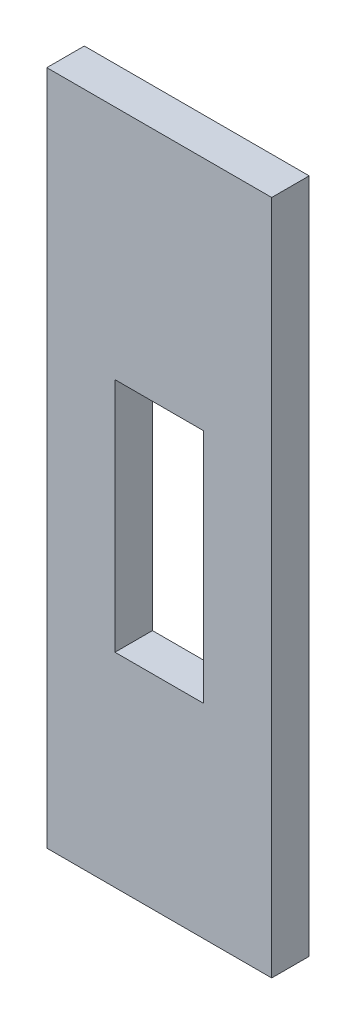
from build123d import *

# Parameters (mm, degrees)
SKETCH1_W           = 38.1
SKETCH1_H           = 114.522810711
SKETCH1_W_2         = 15
SKETCH1_H_2         = 40
BOSS_EXTRUDE1_DEPTH = 6.35


with BuildPart() as part:
    # Sketch1 → Boss-Extrude1 (new body)
    with BuildSketch(Plane.XY):
        with Locations((-12.7, -186.631990495)):
            Rectangle(SKETCH1_W, SKETCH1_H)
        with Locations((-12.7, -189.370585139)):
            Rectangle(SKETCH1_W_2, SKETCH1_H_2, mode=Mode.SUBTRACT)
    extrude(amount=BOSS_EXTRUDE1_DEPTH)


solid = part.part
